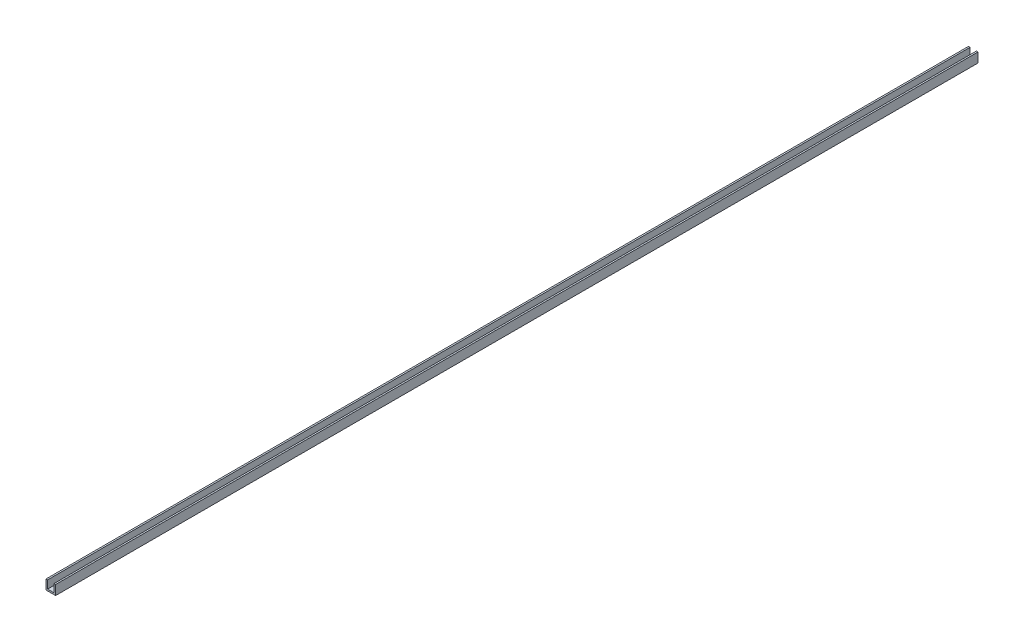
from build123d import *

# Parameters (mm, degrees)
BOSS_EXTRUDE1_DEPTH = 1828.8


with BuildPart() as part:
    # Sketch1 → Boss-Extrude1 (new body)
    with BuildSketch(Plane.XY):
        Polygon((0, 0), (0, -19.05), (19.05, -19.05), (19.05, 0), (15.875, 0), (15.875, -15.875), (3.175, -15.875), (3.175, 0), align=None)
    extrude(amount=BOSS_EXTRUDE1_DEPTH)


solid = part.part
